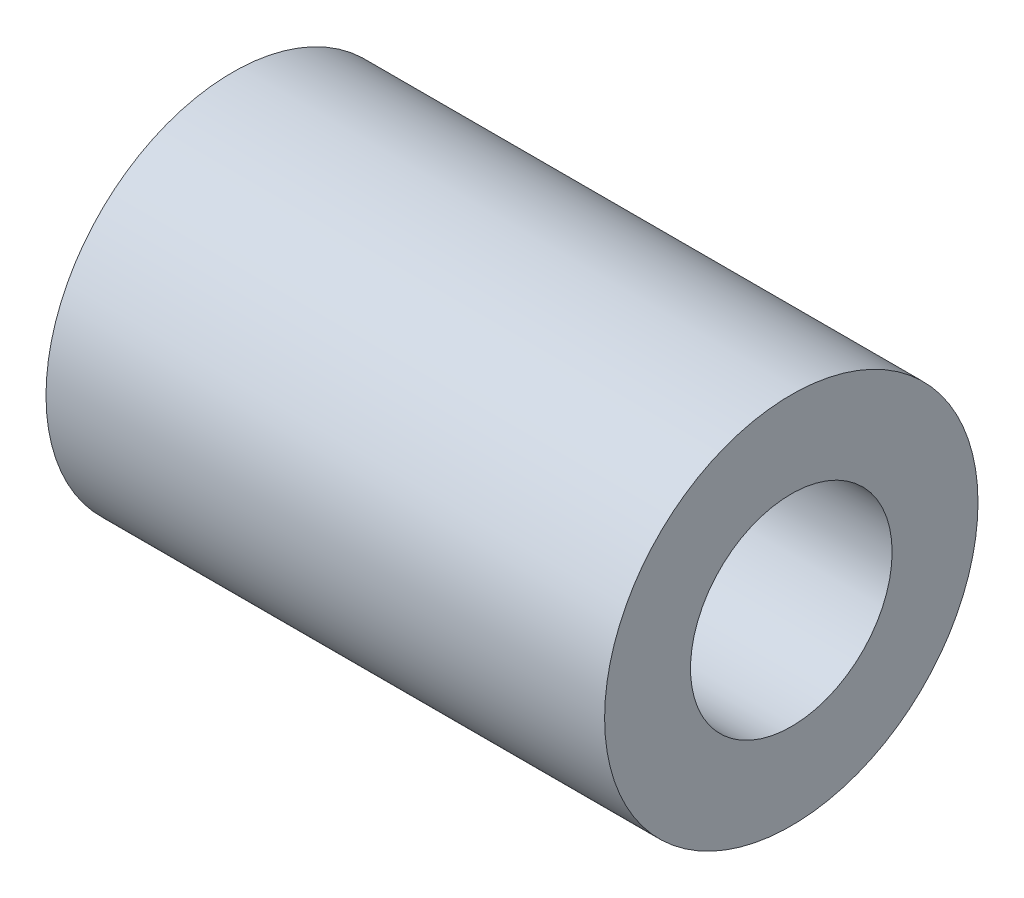
from build123d import *

# Parameters (mm, degrees)
ESQUISSE1_R        = 6.35
ESQUISSE1_R_2      = 3.429
BOSS_EXTRU_1_DEPTH = 19


with BuildPart() as part:
    # Esquisse1 → Boss.-Extru.1 (new body)
    with BuildSketch(Plane(origin=(0, 0, 0), x_dir=(0, 0, -1), z_dir=(1, 0, 0))):
        Circle(ESQUISSE1_R)
        Circle(ESQUISSE1_R_2, mode=Mode.SUBTRACT)
    extrude(amount=-BOSS_EXTRU_1_DEPTH)


solid = part.part
